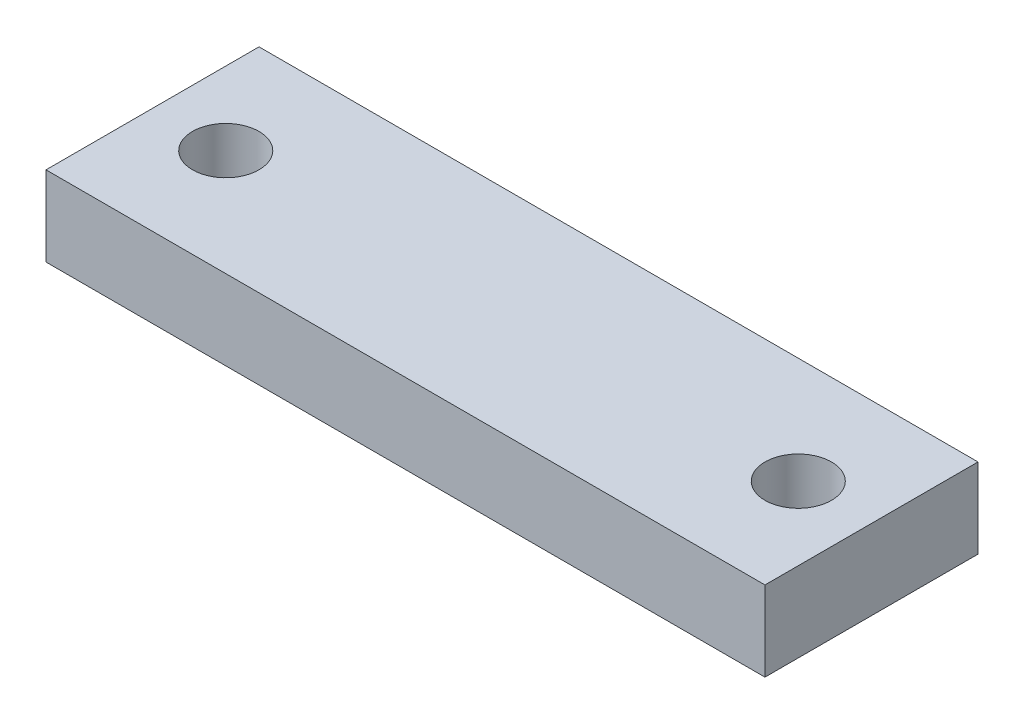
from build123d import *

# Parameters (mm, degrees)
SKETCH1_W      = 85.725
SKETCH1_H      = 25.4
SKETCH1_R      = 3.96875
EXTRUDE1_DEPTH = 9.525


with BuildPart() as part:
    # Sketch1 → Extrude1 (new body)
    with BuildSketch(Plane(origin=(0, 0, 0), x_dir=(1, 0, 0), z_dir=(0, 1, 0))):
        with Locations((42.8625, 12.7)):
            Rectangle(SKETCH1_W, SKETCH1_H)
        with Locations((76.99375, 12.7)):
            Circle(SKETCH1_R, mode=Mode.SUBTRACT)
        with Locations((8.73125, 12.7)):
            Circle(SKETCH1_R, mode=Mode.SUBTRACT)
    extrude(amount=EXTRUDE1_DEPTH)


solid = part.part
